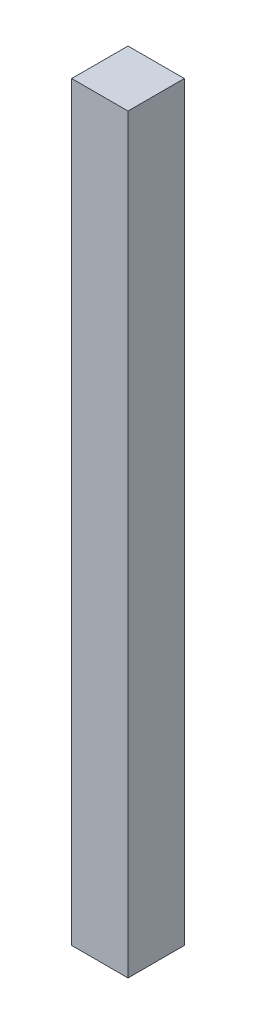
from build123d import *

# Parameters (mm, degrees)
SKETCH1_W           = 15
SKETCH1_H           = 15
BOSS_EXTRUDE1_DEPTH = 200


with BuildPart() as part:
    # Sketch1 → Boss-Extrude1 (new body)
    with BuildSketch(Plane(origin=(0, 0, 0), x_dir=(1, 0, 0), z_dir=(0, 1, 0))):
        Rectangle(SKETCH1_W, SKETCH1_H)
    extrude(amount=BOSS_EXTRUDE1_DEPTH)


solid = part.part
